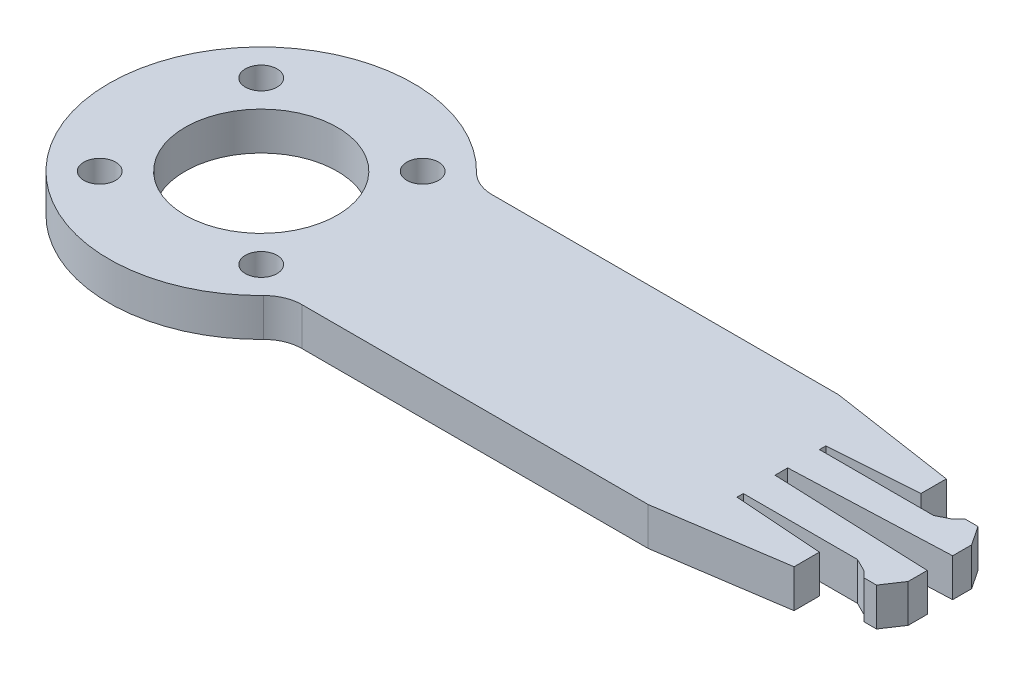
from build123d import *

# Parameters (mm, degrees)
SKETCH1_R           = 6
SKETCH1_R_2         = 1.25
BOSS_EXTRUDE1_DEPTH = 1.5
FILLET1_R           = 3


with BuildPart() as part:
    # Sketch1 → Boss-Extrude1 (new body, symmetric)
    with BuildSketch(Plane(origin=(0, 0, 0), x_dir=(1, 0, 0), z_dir=(0, 1, 0))):
        with BuildLine():
            Line((9.367496998, 7.5), (38, 7.5))
            Line((38, 7.5), (48, 6))
            Line((48, 6), (48, 4))
            Line((48, 4), (41, 3.5))
            Line((41, 3.5), (41, 3))
            Line((41, 3), (50, 3))
            Line((50, 3), (51, 3.5))
            Line((51, 3.5), (51.5, 4))
            Line((51.5, 4), (52.5, 4))
            Line((52.5, 4), (53.5, 2.5))
            Line((53.5, 2.5), (53.5, 1))
            Line((53.5, 1), (41, 0.5))
            Line((41, 0.5), (41, -0.5))
            Line((41, -0.5), (53.5, -1))
            Line((53.5, -1), (53.5, -2.5))
            Line((53.5, -2.5), (52.5, -4))
            Line((52.5, -4), (51.5, -4))
            Line((51.5, -4), (51, -3.5))
            Line((51, -3.5), (50, -3))
            Line((50, -3), (41, -3))
            Line((41, -3), (41, -3.5))
            Line((41, -3.5), (48, -4))
            Line((48, -4), (48, -6))
            Line((48, -6), (38, -7.5))
            Line((38, -7.5), (9.367496998, -7.5))
            ThreePointArc((9.367496998, -7.5), (-12, 0), (9.367496998, 7.5))
        make_face()
        Circle(SKETCH1_R, mode=Mode.SUBTRACT)
        with Locations((6.363961031, 6.363961031)):
            Circle(SKETCH1_R_2, mode=Mode.SUBTRACT)
        with Locations((-6.363961031, 6.363961031)):
            Circle(SKETCH1_R_2, mode=Mode.SUBTRACT)
        with Locations((-6.363961031, -6.363961031)):
            Circle(SKETCH1_R_2, mode=Mode.SUBTRACT)
        with Locations((6.363961031, -6.363961031)):
            Circle(SKETCH1_R_2, mode=Mode.SUBTRACT)
    extrude(amount=BOSS_EXTRUDE1_DEPTH, both=True)

    # Fillet1
    fillet1_edges = [part.edges().sort_by_distance(p)[0] for p in [
        (9.367496998, 0, 7.5),
        (9.367496998, 0, -7.5),
    ]]
    fillet(fillet1_edges, radius=FILLET1_R)


solid = part.part
